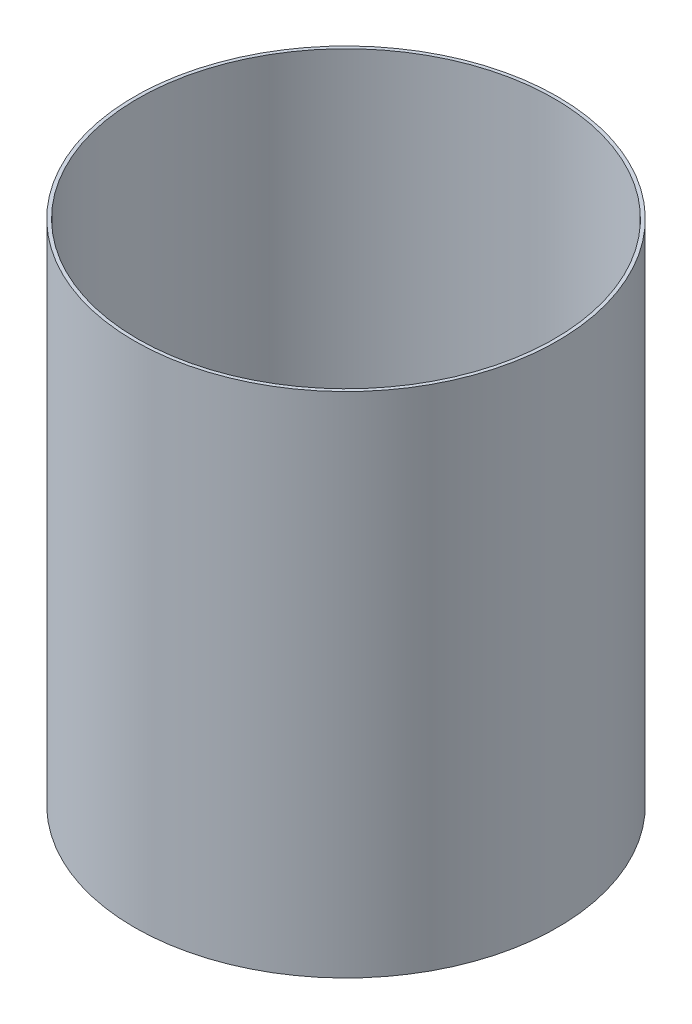
from build123d import *

# Parameters (mm, degrees)
SKETCH1_R           = 125
SKETCH1_R_2         = 123
BOSS_EXTRUDE1_DEPTH = 300


with BuildPart() as part:
    # Sketch1 → Boss-Extrude1 (new body)
    with BuildSketch(Plane(origin=(0, 0, 0), x_dir=(1, 0, 0), z_dir=(0, 1, 0))):
        Circle(SKETCH1_R)
        Circle(SKETCH1_R_2, mode=Mode.SUBTRACT)
    extrude(amount=BOSS_EXTRUDE1_DEPTH)


solid = part.part
